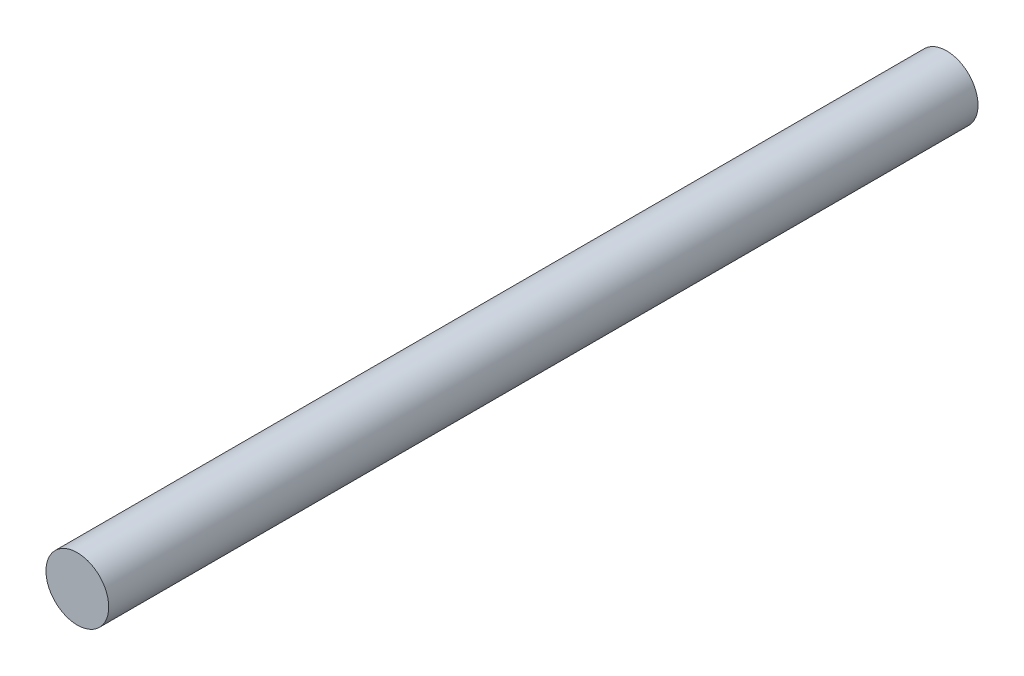
from build123d import *

# Parameters (mm, degrees)
SKETCH_1_R      = 0.325
EXTRUDE_1_DEPTH = 9


with BuildPart() as part:
    # 草图1 → 凸台-拉伸1 (new body)
    with BuildSketch(Plane.XY):
        Circle(SKETCH_1_R)
    extrude(amount=EXTRUDE_1_DEPTH)


solid = part.part
